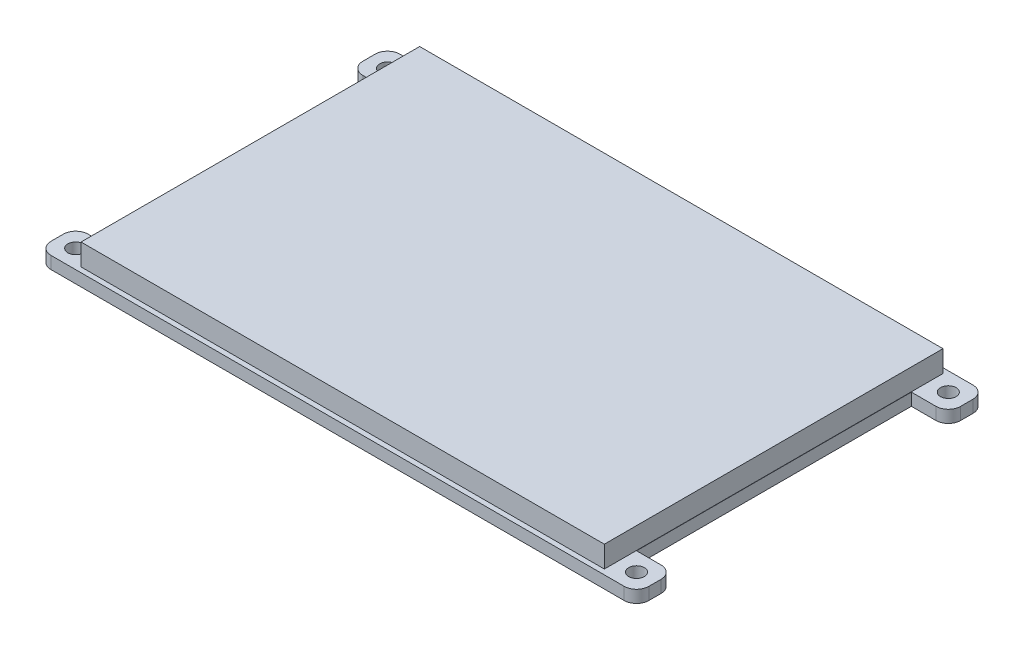
from build123d import *

# Parameters (mm, degrees)
SKETCH1_W            = 85.09
SKETCH1_H            = 56.64
BOSS_EXTRUDE1_DEPTH  = 2
SKETCH3_W            = 6
SKETCH3_H            = 2
BOSS_EXTRUDE4_DEPTH  = 6
SKETCH4_R            = 1.27
CUT_EXTRUDE3_DEPTH   = 6
SKETCH5_W            = 6
SKETCH5_H            = 2
BOSS_EXTRUDE5_DEPTH  = 6
SKETCH7_R            = 1.27
CUT_EXTRUDE4_DEPTH   = 6
SKETCH8_W            = 6
SKETCH8_H            = 2
BOSS_EXTRUDE6_DEPTH  = 6
SKETCH9_W            = 6
SKETCH9_H            = 2
BOSS_EXTRUDE7_DEPTH  = 6
SKETCH10_R           = 1.27
CUT_EXTRUDE5_DEPTH   = 6
SKETCH11_R           = 1.27
CUT_EXTRUDE6_DEPTH   = 6
FILLET5_R            = 2
SKETCH12_W           = 33.5
SKETCH12_H           = 5.2
BOSS_EXTRUDE8_DEPTH  = 15
SKETCH14_W           = 33.4
SKETCH14_H           = 5
CUT_EXTRUDE9_DEPTH   = 6
SKETCH15_W           = 5
SKETCH15_H           = 33
BOSS_EXTRUDE9_DEPTH  = 9
SKETCH16_W           = 85
SKETCH16_H           = 55
BOSS_EXTRUDE10_DEPTH = 3.5


with BuildPart() as part:
    # Sketch1 → Boss-Extrude1 (new body)
    with BuildSketch(Plane(origin=(0, 0, 0), x_dir=(1, 0, 0), z_dir=(0, 1, 0))):
        Rectangle(SKETCH1_W, SKETCH1_H)
    extrude(amount=BOSS_EXTRUDE1_DEPTH)

    # Sketch3 → Boss-Extrude4 (add)
    with BuildSketch(Plane(origin=(42.545, 0, 0), x_dir=(0, 0, -1), z_dir=(1, 0, 0))):
        with Locations((-25.32, 1)):
            Rectangle(SKETCH3_W, SKETCH3_H)
    extrude(amount=BOSS_EXTRUDE4_DEPTH)

    # Sketch4 → Cut-Extrude3 (cut)
    with BuildSketch(Plane(origin=(0, 2, 0), x_dir=(1, 0, 0), z_dir=(0, 1, 0))):
        with Locations((45.545, -25.32)):
            Circle(SKETCH4_R)
    extrude(amount=-CUT_EXTRUDE3_DEPTH, mode=Mode.SUBTRACT)

    # Sketch5 → Boss-Extrude5 (add)
    with BuildSketch(Plane(origin=(42.545, 0, 0), x_dir=(0, 0, -1), z_dir=(1, 0, 0))):
        with Locations((25.32, 1)):
            Rectangle(SKETCH5_W, SKETCH5_H)
    extrude(amount=BOSS_EXTRUDE5_DEPTH)

    # Sketch7 → Cut-Extrude4 (cut)
    with BuildSketch(Plane(origin=(0, 2, 0), x_dir=(1, 0, 0), z_dir=(0, 1, 0))):
        with Locations((45.545, 25.32)):
            Circle(SKETCH7_R)
    extrude(amount=-CUT_EXTRUDE4_DEPTH, mode=Mode.SUBTRACT)

    # Sketch8 → Boss-Extrude6 (add)
    with BuildSketch(Plane.ZY.offset(42.545)):
        with Locations((-25.32, 1)):
            Rectangle(SKETCH8_W, SKETCH8_H)
    extrude(amount=BOSS_EXTRUDE6_DEPTH)

    # Sketch9 → Boss-Extrude7 (add)
    with BuildSketch(Plane.ZY.offset(42.545)):
        with Locations((25.32, 1)):
            Rectangle(SKETCH9_W, SKETCH9_H)
    extrude(amount=BOSS_EXTRUDE7_DEPTH)

    # Sketch10 → Cut-Extrude5 (cut)
    with BuildSketch(Plane(origin=(0, 2, 0), x_dir=(1, 0, 0), z_dir=(0, 1, 0))):
        with Locations((-45.545, 25.32)):
            Circle(SKETCH10_R)
    extrude(amount=-CUT_EXTRUDE5_DEPTH, mode=Mode.SUBTRACT)

    # Sketch11 → Cut-Extrude6 (cut)
    with BuildSketch(Plane(origin=(0, 2, 0), x_dir=(1, 0, 0), z_dir=(0, 1, 0))):
        with Locations((-45.545, -25.32)):
            Circle(SKETCH11_R)
    extrude(amount=-CUT_EXTRUDE6_DEPTH, mode=Mode.SUBTRACT)

    # Fillet5
    fillet5_edges = [part.edges().sort_by_distance(p)[0] for p in [
        (48.545, 1, 28.32),
        (48.545, 1, 22.32),
        (48.545, 1, -28.32),
        (48.545, 1, -22.32),
        (-48.545, 1, -28.32),
        (-48.545, 1, -22.32),
        (-48.545, 1, 28.32),
        (-48.545, 1, 22.32),
    ]]
    fillet(fillet5_edges, radius=FILLET5_R)

    # Sketch12 → Boss-Extrude8 (add)
    with BuildSketch(Plane.XZ):
        with Locations((-24.795, -24.72)):
            Rectangle(SKETCH12_W, SKETCH12_H)
    extrude(amount=BOSS_EXTRUDE8_DEPTH)

    # Sketch14 → Cut-Extrude9 (cut)
    with BuildSketch(Plane.XZ.offset(15)):
        with Locations((-24.845, -24.72)):
            Rectangle(SKETCH14_W, SKETCH14_H)
    extrude(amount=-CUT_EXTRUDE9_DEPTH, mode=Mode.SUBTRACT)

    # Sketch15 → Boss-Extrude9 (add)
    with BuildSketch(Plane.XZ):
        with Locations((-37.045, 0.82)):
            Rectangle(SKETCH15_W, SKETCH15_H)
    extrude(amount=BOSS_EXTRUDE9_DEPTH)

    # Sketch16 → Boss-Extrude10 (add)
    with BuildSketch(Plane(origin=(0, 2, 0), x_dir=(1, 0, 0), z_dir=(0, 1, 0))):
        Rectangle(SKETCH16_W, SKETCH16_H)
    extrude(amount=BOSS_EXTRUDE10_DEPTH)


solid = part.part
